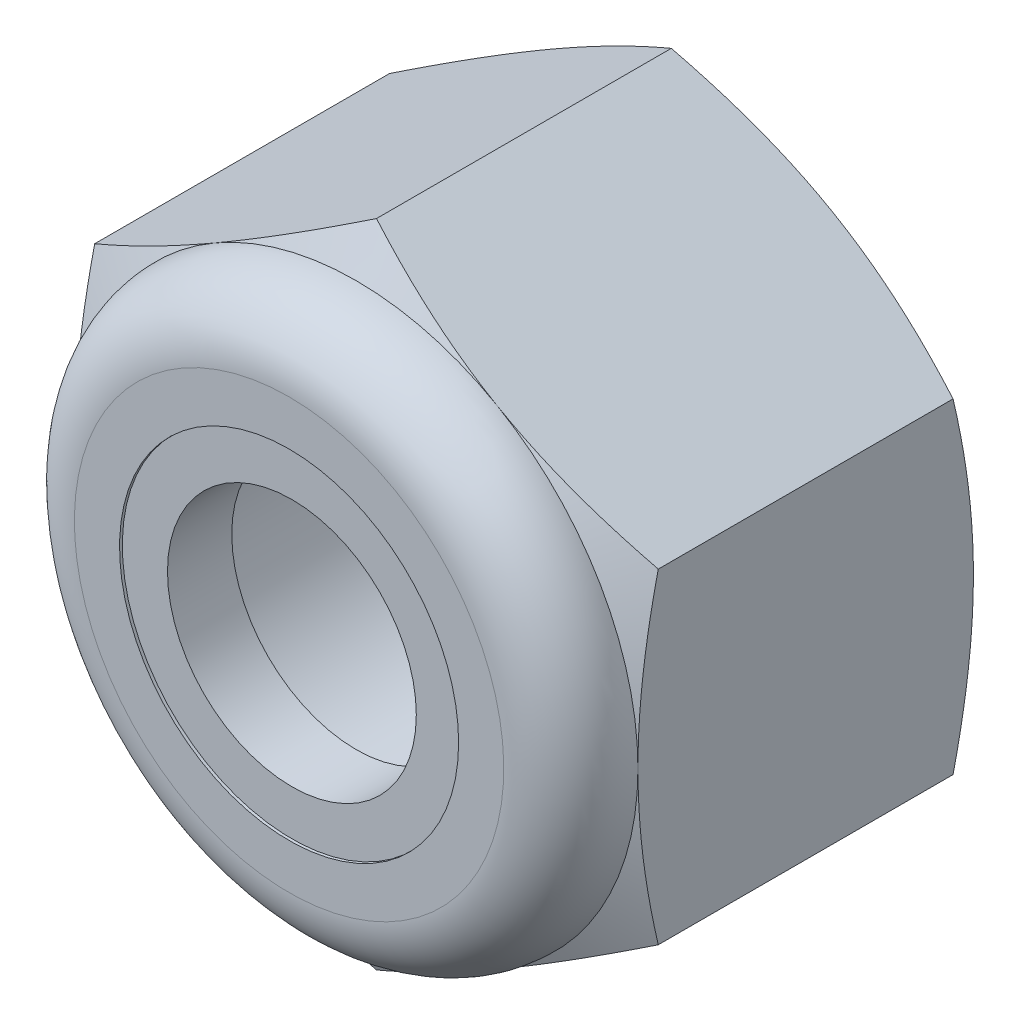
from build123d import *

# Parameters (mm, degrees)
SKETCH3_R           = 2
BOSS_EXTRUDE1_DEPTH = 2.5


with BuildPart() as part:
    # Sketch3 → Boss-Extrude1 (new body, symmetric)
    with BuildSketch(Plane.XY):
        Polygon((0, -4.041451884), (3.5, -2.020725942), (3.5, 2.020725942), (0, 4.041451884), (-3.5, 2.020725942), (-3.5, -2.020725942), align=None)
        Circle(SKETCH3_R, mode=Mode.SUBTRACT)
    extrude(amount=BOSS_EXTRUDE1_DEPTH, both=True)

    # Sketch4 → Cut-Revolve1 (revolve, cut)
    with BuildSketch(Plane(origin=(0, 0, 0), x_dir=(0, 0, -1), z_dir=(1, 0, 0))):
        with BuildLine():
            Line((3.77, 5.311451884), (-3.77, 5.311451884))
            Line((-3.77, 5.311451884), (-3.77, 2.666666667))
            Line((-3.77, 2.666666667), (-2.5, 2.666666667))
            ThreePointArc((-2.5, 2.666666667), (-2.255922318, 3.255922318), (-1.666666667, 3.5))
            Line((-1.666666667, 3.5), (-1.414183506, 4.041451884))
            Line((-1.414183506, 4.041451884), (2.24751684, 4.041451884))
            Line((2.24751684, 4.041451884), (2.5, 3.5))
            Line((2.5, 3.5), (2.5, 0))
            Line((2.5, 0), (3.77, 0))
            Line((3.77, 0), (3.77, 5.311451884))
        make_face()
        with BuildLine():
            Line((-3.77, 2.106001665), (-3.77, 0))
            Line((-3.77, 0), (-1.666666667, 0))
            Line((-1.666666667, 0), (-1.666666667, 3.465))
            ThreePointArc((-1.666666667, 3.465), (-2.23117358, 3.23117358), (-2.465, 2.666666667))
            Line((-2.465, 2.666666667), (-2.465, 2.106001665))
            Line((-2.465, 2.106001665), (-3.77, 2.106001665))
        make_face()
    revolve(axis=Axis((0, 0, -2.5), (0, 0, 1)), mode=Mode.SUBTRACT)


with BuildPart() as body_2:
    # Sketch5 → Revolve1 (revolve)
    with BuildSketch(Plane(origin=(0, 0, 0), x_dir=(0, 0, -1), z_dir=(1, 0, 0))):
        with BuildLine():
            Line((-2.465, 2.666666667), (-2.465, 1.545336663))
            Line((-2.465, 1.545336663), (-1.666666667, 1.545336663))
            Line((-1.666666667, 1.545336663), (-1.666666667, 3.465))
            ThreePointArc((-1.666666667, 3.465), (-2.23117358, 3.23117358), (-2.465, 2.666666667))
        make_face()
    revolve(axis=Axis((0, 0, -2.5), (0, 0, 1)))


solid = Compound([part.part, body_2.part])
